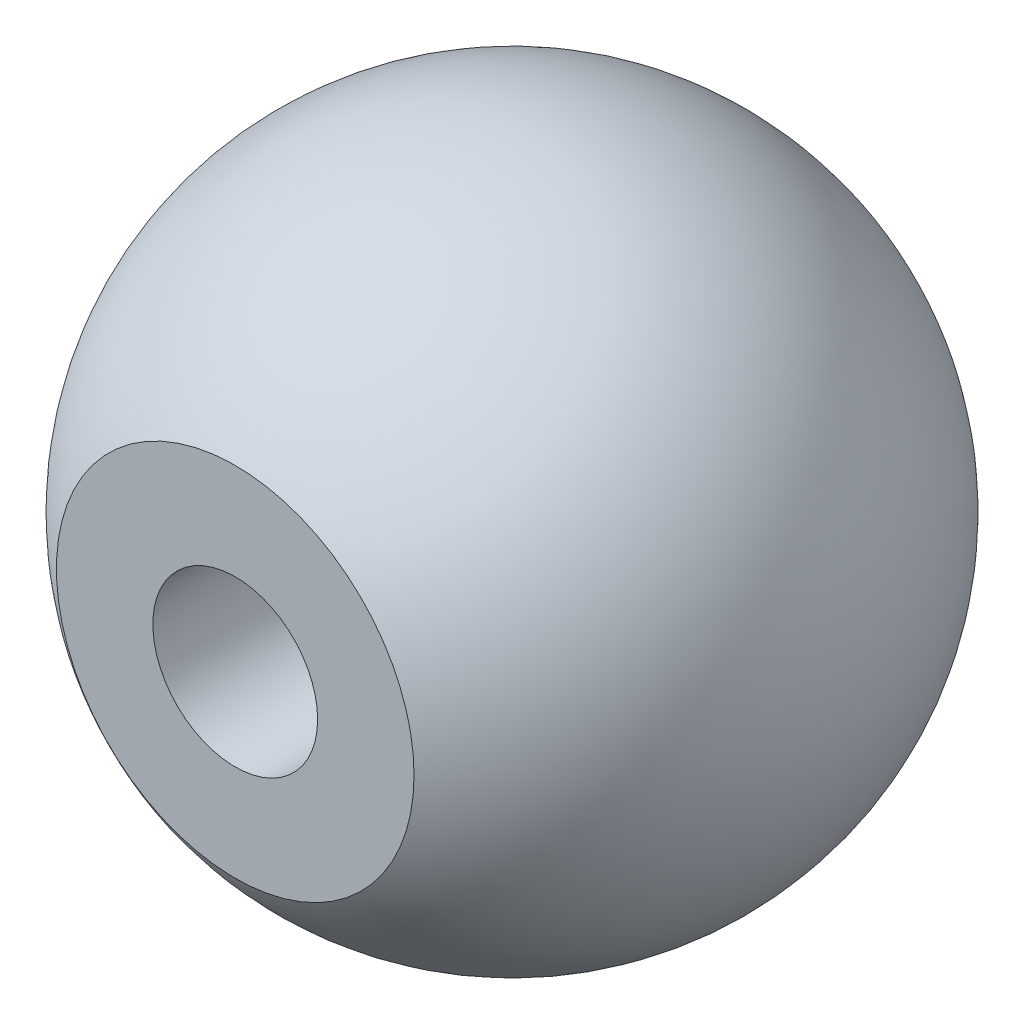
from build123d import *

# Parameters (mm, degrees)
SKETCH3_W          = 37.025629418
SKETCH3_H          = 29.353652152
CUT_EXTRUDE1_DEPTH = 3.048
SKETCH4_R          = 4.7625
CUT_EXTRUDE2_DEPTH = 12.7


with BuildPart() as part:
    # Sketch1 → Revolve6 (revolve)
    with BuildSketch(Plane(origin=(0, 0, 0), x_dir=(1, 0, 0), z_dir=(0, 1, 0))):
        with BuildLine():
            Line((0, 0), (19.05, 0))
            ThreePointArc((19.05, 0), (0, -19.05), (-19.05, 0))
            Line((-19.05, 0), (0, 0))
        make_face()
    revolve(axis=Axis((-19.05, 0, 0), (1, 0, 0)))

    # Sketch3 → Cut-Extrude1 (cut)
    with BuildSketch(Plane.XY.offset(16.002)):
        Rectangle(SKETCH3_W, SKETCH3_H)
    extrude(amount=CUT_EXTRUDE1_DEPTH, mode=Mode.SUBTRACT)

    # Sketch4 → Cut-Extrude2 (cut)
    with BuildSketch(Plane.XY.offset(16.002)):
        Circle(SKETCH4_R)
    extrude(amount=-CUT_EXTRUDE2_DEPTH, mode=Mode.SUBTRACT)


solid = part.part
